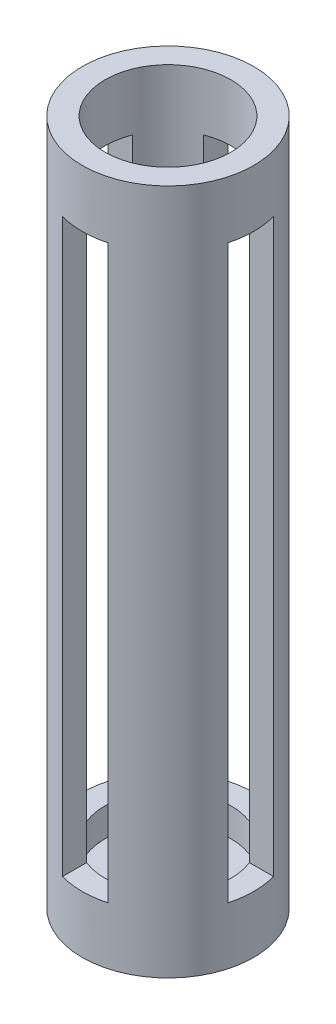
from build123d import *

# Parameters (mm, degrees)
SKETCH1_R               = 19.05
SKETCH1_R_2             = 13.97
BOSS_EXTRUDE1_DEPTH     = 152.4
SKETCH2_R               = 13.97
BOSS_EXTRUDE2_DEPTH     = 6.35
SKETCH3_R               = 2.2479
CUT_EXTRUDE1_DEPTH      = 3.54
CUT_EXTRUDE1_DEPTH_BACK = 36.56
SKETCH5_W               = 10.16
SKETCH5_H               = 127
CUT_EXTRUDE5_DEPTH      = 20.0500001
CUT_EXTRUDE5_DEPTH_BACK = 20.0500001
SKETCH8_W               = 10.16
SKETCH8_H               = 127
CUT_EXTRUDE6_DEPTH      = 20.050000101
CUT_EXTRUDE6_DEPTH_BACK = 20.050000101
SKETCH7_R               = 6.35
CUT_EXTRUDE4_DEPTH      = 7.35
SKETCH9_R               = 8.89
SKETCH9_R_2             = 6.35
BOSS_EXTRUDE3_DEPTH     = 19.05
SKETCH10_R              = 8.89
SKETCH10_R_2            = 5.08
BOSS_EXTRUDE4_DEPTH     = 5.08


with BuildPart() as part:
    # Sketch1 → Boss-Extrude1 (new body)
    with BuildSketch(Plane(origin=(0, 0, 0), x_dir=(1, 0, 0), z_dir=(0, 1, 0))):
        Circle(SKETCH1_R)
        Circle(SKETCH1_R_2, mode=Mode.SUBTRACT)
    extrude(amount=BOSS_EXTRUDE1_DEPTH)

    # Sketch2 → Boss-Extrude2 (add)
    with BuildSketch(Plane.XZ):
        Circle(SKETCH2_R)
    extrude(amount=-BOSS_EXTRUDE2_DEPTH)

    # Sketch3 → Cut-Extrude1 (cut, two sides)
    with BuildSketch(Plane.XY.offset(16.51)) as cut_extrude1_sk:
        with Locations((0, 101.6)):
            Circle(SKETCH3_R)
    extrude(amount=CUT_EXTRUDE1_DEPTH, mode=Mode.SUBTRACT)
    extrude(cut_extrude1_sk.sketch, amount=-CUT_EXTRUDE1_DEPTH_BACK, mode=Mode.SUBTRACT)

    # Sketch5 → Cut-Extrude5 (cut, two sides)
    with BuildSketch(Plane(origin=(0, 0, 0), x_dir=(0, 0, -1), z_dir=(1, 0, 0))) as cut_extrude5_sk:
        with Locations((0, 76.2)):
            Rectangle(SKETCH5_W, SKETCH5_H)
    extrude(amount=CUT_EXTRUDE5_DEPTH, mode=Mode.SUBTRACT)
    extrude(cut_extrude5_sk.sketch, amount=-CUT_EXTRUDE5_DEPTH_BACK, mode=Mode.SUBTRACT)

    # Sketch8 → Cut-Extrude6 (cut, two sides)
    with BuildSketch(Plane.XY) as cut_extrude6_sk:
        with Locations((0, 76.2)):
            Rectangle(SKETCH8_W, SKETCH8_H)
    extrude(amount=CUT_EXTRUDE6_DEPTH, mode=Mode.SUBTRACT)
    extrude(cut_extrude6_sk.sketch, amount=-CUT_EXTRUDE6_DEPTH_BACK, mode=Mode.SUBTRACT)

    # Sketch7 → Cut-Extrude4 (cut, through all)
    with BuildSketch(Plane(origin=(0, 6.35, 0), x_dir=(1, 0, 0), z_dir=(0, 1, 0))):
        Circle(SKETCH7_R)
    extrude(amount=-CUT_EXTRUDE4_DEPTH, mode=Mode.SUBTRACT)

    # Sketch9 → Boss-Extrude3 (add)
    with BuildSketch(Plane(origin=(0, 6.35, 0), x_dir=(1, 0, 0), z_dir=(0, 1, 0))):
        Circle(SKETCH9_R)
        Circle(SKETCH9_R_2, mode=Mode.SUBTRACT)
    extrude(amount=BOSS_EXTRUDE3_DEPTH)

    # Sketch10 → Boss-Extrude4 (add)
    with BuildSketch(Plane(origin=(0, 25.4, 0), x_dir=(1, 0, 0), z_dir=(0, 1, 0))):
        Circle(SKETCH10_R)
        Circle(SKETCH10_R_2, mode=Mode.SUBTRACT)
    extrude(amount=BOSS_EXTRUDE4_DEPTH)


solid = part.part
